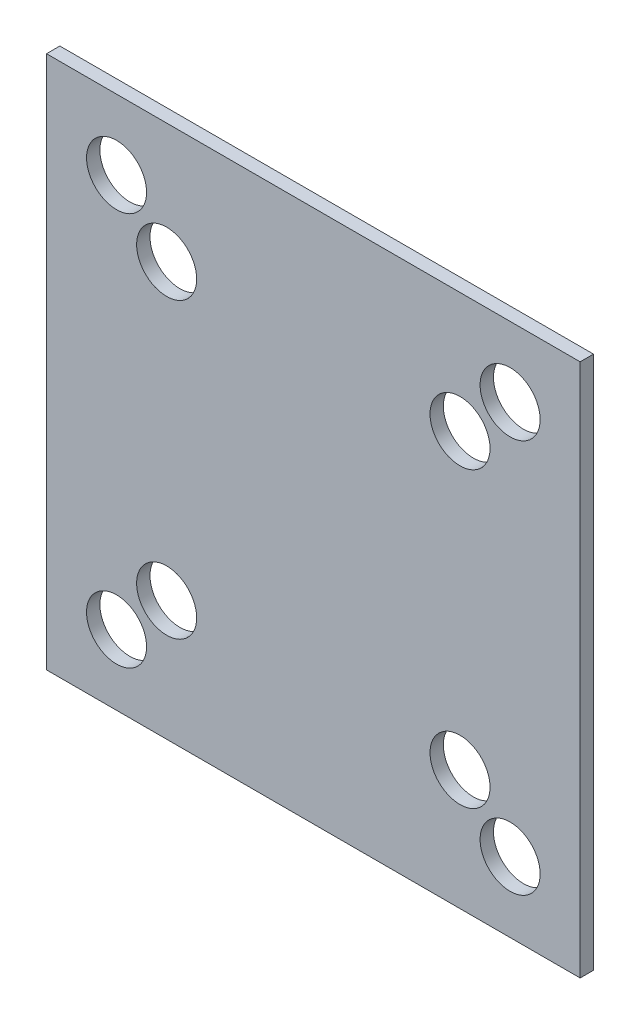
from build123d import *

# Parameters (mm, degrees)
SKETCH_1_W          = 80
SKETCH_1_H          = 80
EXTRUDE_1_DEPTH     = 2
CUT_EXTRUDE_1_DEPTH = 10


with BuildPart() as part:
    # ｽｹｯﾁ1 → ﾎﾞｽ - 押し出し1 (new body)
    with BuildSketch(Plane.XY):
        Rectangle(SKETCH_1_W, SKETCH_1_H)
    extrude(amount=EXTRUDE_1_DEPTH)

    # ｽｹｯﾁ2 → ｶｯﾄ - 押し出し1 (cut)
    with BuildSketch(Plane.XY.offset(2)):
        with BuildLine():
            ThreePointArc((29.5, -25), (26.318019485, -26.318019485), (25, -29.5))
            Line((25, -29.5), (29.5, -29.5))
            Line((29.5, -29.5), (29.5, -25))
        make_face()
        with BuildLine():
            Line((29.5, -29.5), (25, -29.5))
            ThreePointArc((25, -29.5), (29.5, -34), (34, -29.5))
            ThreePointArc((34, -29.5), (32.681980515, -26.318019485), (29.5, -25))
            Line((29.5, -25), (29.5, -29.5))
        make_face()
        with BuildLine():
            ThreePointArc((21.99, -17.49), (18.808019485, -18.808019485), (17.49, -21.99))
            Line((17.49, -21.99), (21.99, -21.99))
            Line((21.99, -21.99), (21.99, -17.49))
        make_face()
        with BuildLine():
            Line((21.99, -21.99), (17.49, -21.99))
            ThreePointArc((17.49, -21.99), (21.99, -26.49), (26.49, -21.99))
            ThreePointArc((26.49, -21.99), (25.171980515, -18.808019485), (21.99, -17.49))
            Line((21.99, -17.49), (21.99, -21.99))
        make_face()
        with BuildLine():
            ThreePointArc((25, 29.5), (26.318019485, 26.318019485), (29.5, 25))
            Line((29.5, 25), (29.5, 29.5))
            Line((29.5, 29.5), (25, 29.5))
        make_face()
        with BuildLine():
            Line((29.5, 29.5), (29.5, 25))
            ThreePointArc((29.5, 25), (32.681980515, 26.318019485), (34, 29.5))
            ThreePointArc((34, 29.5), (29.5, 34), (25, 29.5))
            Line((25, 29.5), (29.5, 29.5))
        make_face()
        with BuildLine():
            ThreePointArc((17.49, 21.99), (18.808019485, 18.808019485), (21.99, 17.49))
            Line((21.99, 17.49), (21.99, 21.99))
            Line((21.99, 21.99), (17.49, 21.99))
        make_face()
        with BuildLine():
            Line((21.99, 21.99), (21.99, 17.49))
            ThreePointArc((21.99, 17.49), (25.171980515, 18.808019485), (26.49, 21.99))
            ThreePointArc((26.49, 21.99), (21.99, 26.49), (17.49, 21.99))
            Line((17.49, 21.99), (21.99, 21.99))
        make_face()
        with BuildLine():
            ThreePointArc((-21.99, -17.49), (-25.171980515, -25.171980515), (-17.49, -21.99))
            Line((-17.49, -21.99), (-21.99, -21.99))
            Line((-21.99, -21.99), (-21.99, -17.49))
        make_face()
        with BuildLine():
            Line((-21.99, -21.99), (-17.49, -21.99))
            ThreePointArc((-17.49, -21.99), (-18.808019485, -18.808019485), (-21.99, -17.49))
            Line((-21.99, -17.49), (-21.99, -21.99))
        make_face()
        with BuildLine():
            ThreePointArc((-29.5, -25), (-32.681980515, -32.681980515), (-25, -29.5))
            Line((-25, -29.5), (-29.5, -29.5))
            Line((-29.5, -29.5), (-29.5, -25))
        make_face()
        with BuildLine():
            Line((-29.5, -29.5), (-25, -29.5))
            ThreePointArc((-25, -29.5), (-26.318019485, -26.318019485), (-29.5, -25))
            Line((-29.5, -25), (-29.5, -29.5))
        make_face()
        with BuildLine():
            ThreePointArc((-17.49, 21.99), (-25.171980515, 25.171980515), (-21.99, 17.49))
            Line((-21.99, 17.49), (-21.99, 21.99))
            Line((-21.99, 21.99), (-17.49, 21.99))
        make_face()
        with BuildLine():
            Line((-21.99, 21.99), (-21.99, 17.49))
            ThreePointArc((-21.99, 17.49), (-18.808019485, 18.808019485), (-17.49, 21.99))
            Line((-17.49, 21.99), (-21.99, 21.99))
        make_face()
        with BuildLine():
            ThreePointArc((-25, 29.5), (-32.681980515, 32.681980515), (-29.5, 25))
            Line((-29.5, 25), (-29.5, 29.5))
            Line((-29.5, 29.5), (-25, 29.5))
        make_face()
        with BuildLine():
            Line((-29.5, 29.5), (-29.5, 25))
            ThreePointArc((-29.5, 25), (-26.318019485, 26.318019485), (-25, 29.5))
            Line((-25, 29.5), (-29.5, 29.5))
        make_face()
    extrude(amount=-CUT_EXTRUDE_1_DEPTH, mode=Mode.SUBTRACT)


solid = part.part
